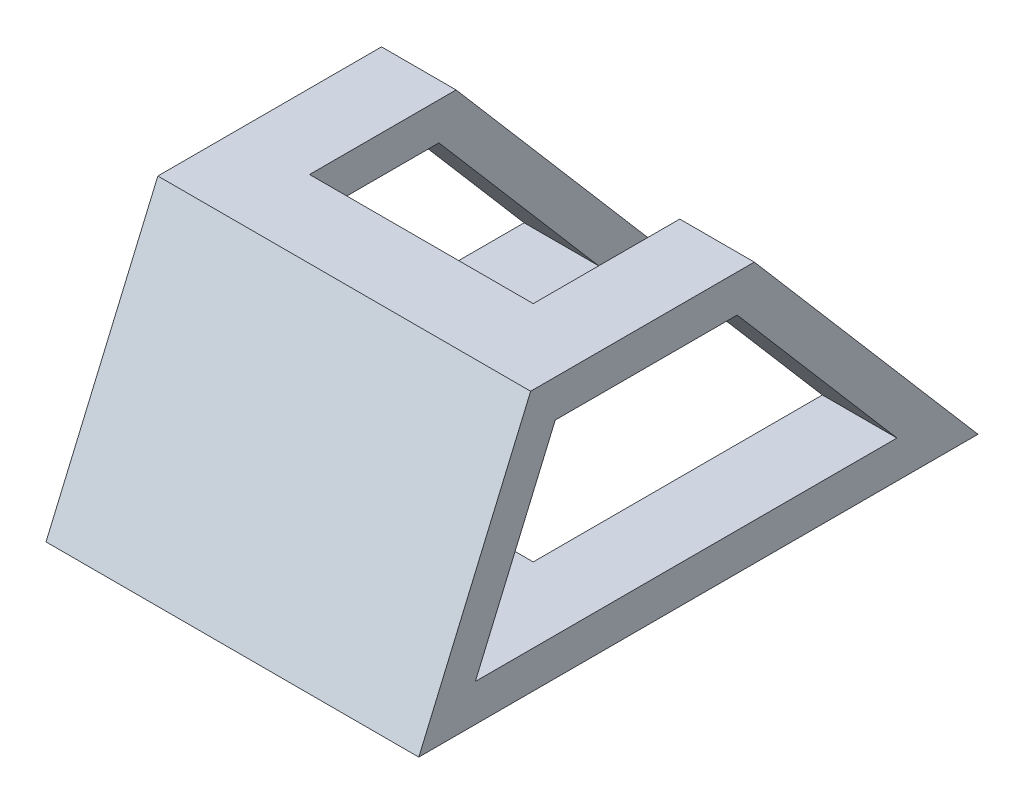
from build123d import *

# Parameters (mm, degrees)
BOSS_EXTRUDE1_DEPTH = 100
SKETCH4_W           = 60
SKETCH4_H           = 100
CUT_EXTRUDE2_DEPTH  = 71


with BuildPart() as part:
    # Sketch1 → Boss-Extrude1 (new body)
    with BuildSketch(Plane(origin=(0, 0, 0), x_dir=(0, 0, -1), z_dir=(1, 0, 0))):
        Polygon((-75, 0), (75, 0), (15, 70), (-45, 70), align=None)
        Polygon((-38.40603842, 60), (10.400650775, 60), (53.257793632, 10), (-59.834609849, 10), align=None, mode=Mode.SUBTRACT)
    extrude(amount=BOSS_EXTRUDE1_DEPTH)

    # Sketch4 → Cut-Extrude2 (cut, through all)
    with BuildSketch(Plane(origin=(0, 70, 0), x_dir=(1, 0, 0), z_dir=(0, 1, 0))):
        with Locations((50, 25.697233142)):
            Rectangle(SKETCH4_W, SKETCH4_H)
    extrude(amount=-CUT_EXTRUDE2_DEPTH, mode=Mode.SUBTRACT)


solid = part.part
